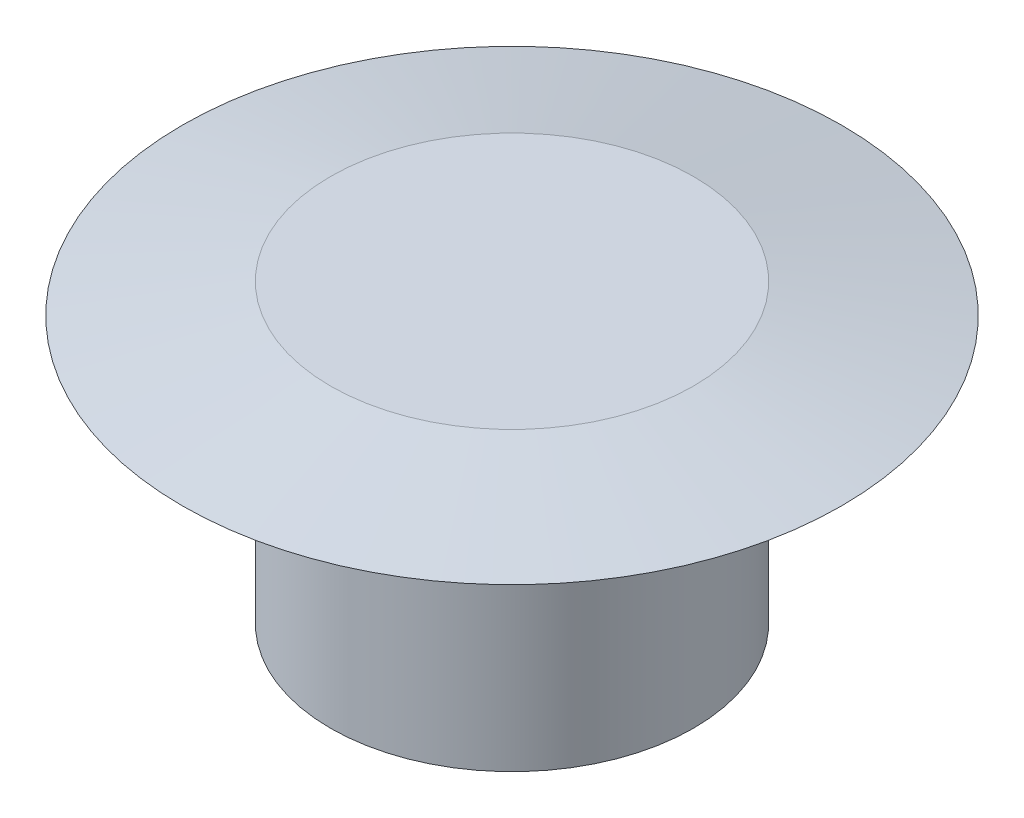
from build123d import *

# Parameters (mm, degrees)
CROQUIS4_R              = 10.9
SALIENTE_EXTRUIR3_DEPTH = 1.35


with BuildPart() as part:
    # Croquis1 → Revolución1 (revolve)
    with BuildSketch(Plane.XY):
        Polygon((-10.9, 20), (-10.9, 0), (-12.25, 0), (-12.25, 18), (-22.25, 18), (-12.25, 20), align=None)
    revolve(axis=Axis((0, 0, 0), (0, 1, 0)))

    # Croquis4 → Saliente-Extruir3 (add)
    with BuildSketch(Plane(origin=(0, 20, 0), x_dir=(1, 0, 0), z_dir=(0, 1, 0))):
        Circle(CROQUIS4_R)
    extrude(amount=-SALIENTE_EXTRUIR3_DEPTH)


solid = part.part
